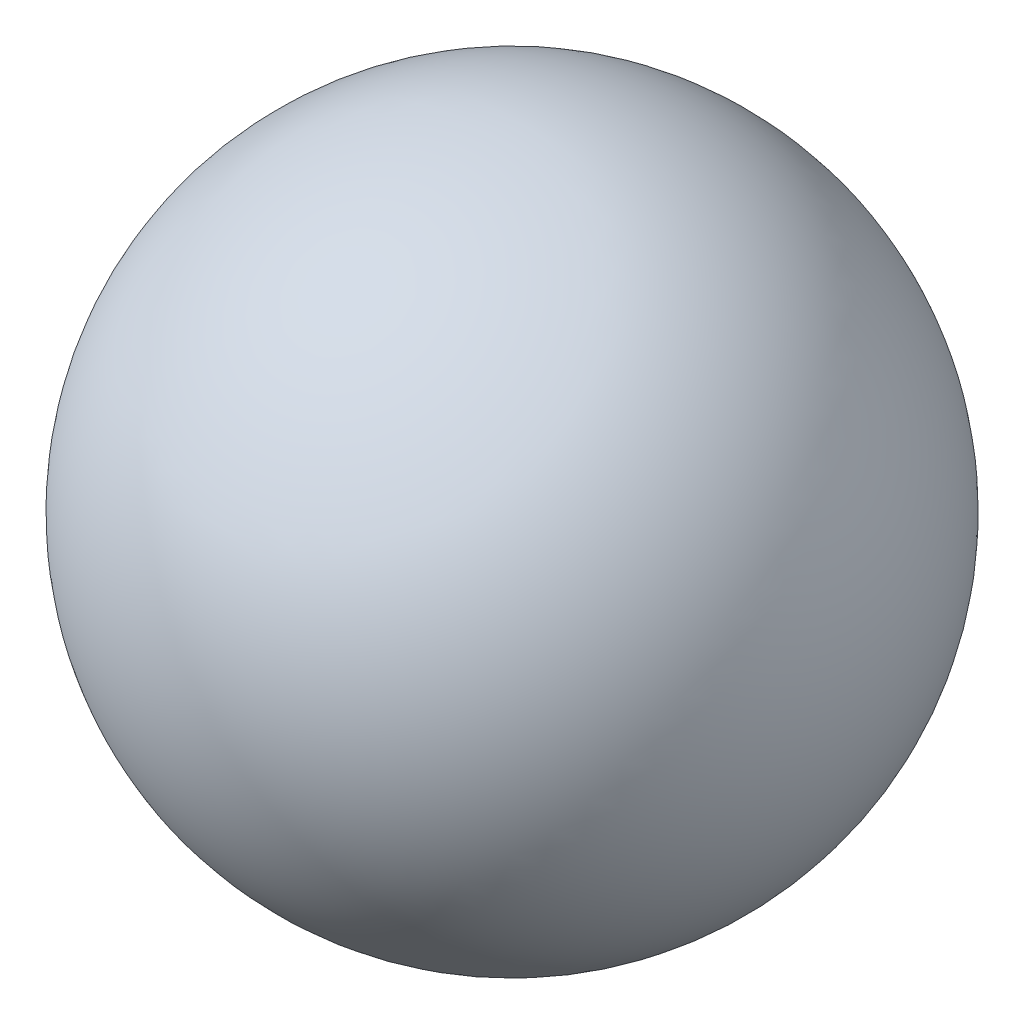
from build123d import *


with BuildPart() as part:
    # 草图1 → 旋转1 (revolve)
    with BuildSketch(Plane(origin=(0, 0, 0), x_dir=(1, 0, 0), z_dir=(0, 1, 0))):
        with BuildLine():
            Line((0, -2), (0, 2))
            ThreePointArc((0, 2), (2, 0), (0, -2))
        make_face()
    revolve(axis=Axis((0, 0, 2), (0, 0, -1)))


solid = part.part
